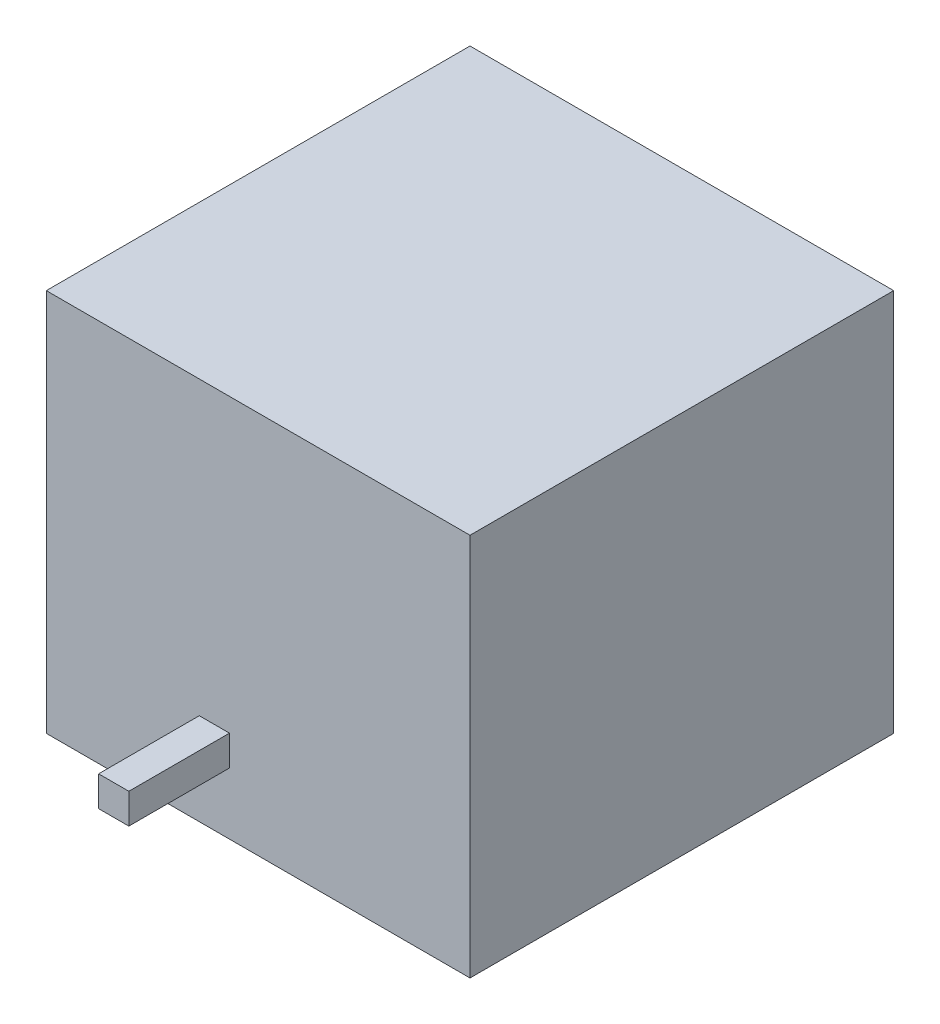
from build123d import *

# Parameters (mm, degrees)
SKETCH2_W           = 42.1
SKETCH2_H           = 42.1
BOSS_EXTRUDE1_DEPTH = 38.1
SKETCH4_W           = 3
SKETCH4_H           = 3
BOSS_EXTRUDE2_DEPTH = 10


with BuildPart() as part:
    # Sketch2 → Boss-Extrude1 (new body)
    with BuildSketch(Plane(origin=(0, 0, 0), x_dir=(1, 0, 0), z_dir=(0, 1, 0))):
        with Locations((21.05, 21.05)):
            Rectangle(SKETCH2_W, SKETCH2_H)
    extrude(amount=BOSS_EXTRUDE1_DEPTH)

    # Sketch4 → Boss-Extrude2 (add)
    with BuildSketch(Plane.XY):
        with Locations((16.7, 7.62)):
            Rectangle(SKETCH4_W, SKETCH4_H)
    extrude(amount=BOSS_EXTRUDE2_DEPTH)


solid = part.part
